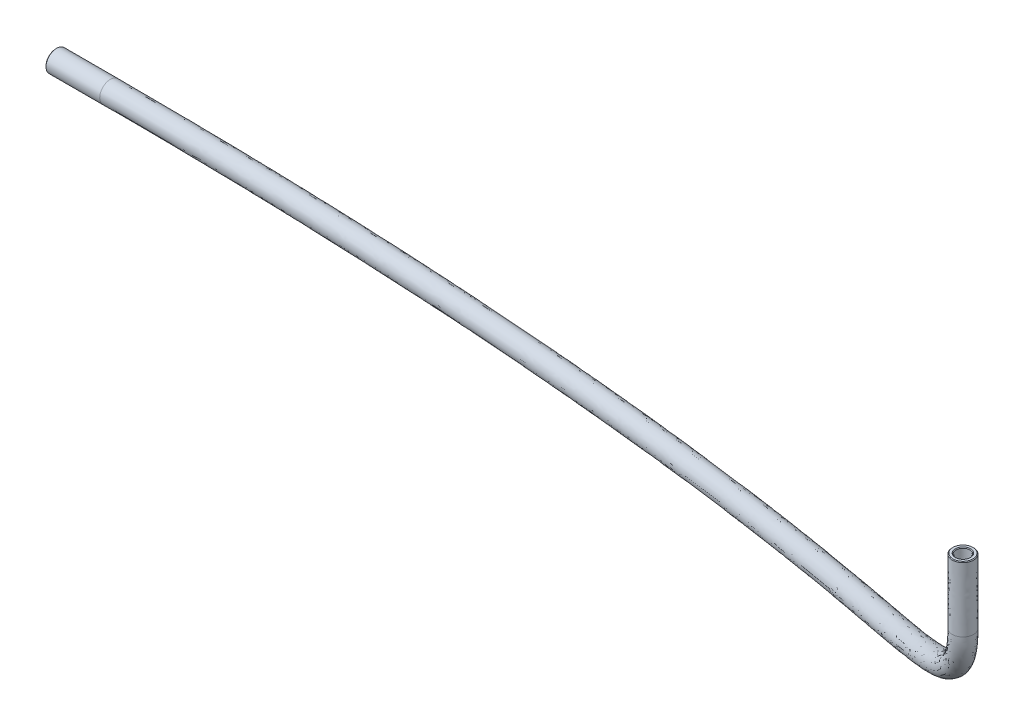
from build123d import *

# Parameters (mm, degrees)
SKETCH1_R     = 2
SKETCH1_R_2   = 1.3
CHAMFER1_SIZE = 0.127


with BuildPart() as part:
    # Sweep1: sweep along a curve in space
    with BuildLine() as sweep1_path:
        Line((-136.885279081, -106.482256564, -25.525), (-147.085279081, -106.482256564, -25.525))
        add(Edge.make_bspline(
            [(62.325, -74.325, 13.85), (62.325, -85.122503373, 13.85), (31.460753901, -98.362999613, -5.8375), (-64.525857192, -106.482256564, -25.525), (-136.885279081, -106.482256564, -25.525)],
            knots=[0, 0, 0, 0, 0.441561755, 1, 1, 1, 1], degree=3))
        Line((62.325, -62.125, 13.85), (62.325, -74.325, 13.85))
    # Sketch1 → Sweep1 (sweep)
    with BuildSketch(Plane(origin=(-139.385279081, 0, 0), x_dir=(0, 0, -1), z_dir=(1, 0, 0))):
        with Locations((25.525, -106.482256564)):
            Circle(SKETCH1_R)
        with Locations((25.525, -106.482256564)):
            Circle(SKETCH1_R_2, mode=Mode.SUBTRACT)
    sweep(path=sweep1_path.line)

    # Chamfer1
    chamfer1_edges = [part.edges().sort_by_distance(p)[0] for p in [
        (61.798548272, -62.125, 15.038633071),
        (-147.085279081, -106.482256564, -24.225),
        (61.515074265, -62.125, 15.678666264),
        (-147.085279081, -106.482256564, -23.525),
    ]]
    chamfer(chamfer1_edges, length=CHAMFER1_SIZE)


solid = part.part
